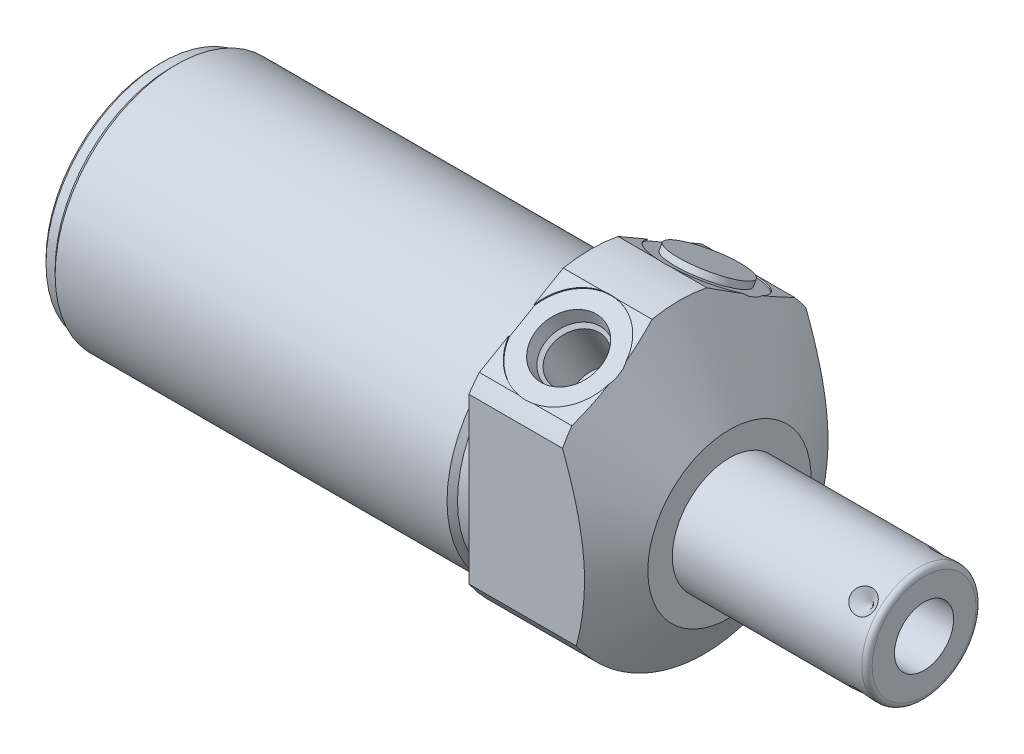
from build123d import *

# Parameters (mm, degrees)
SKETCH1_R           = 28.575
EXTRUDE1_DEPTH      = 27.0002
EXTRUDE1_DEPTH_BACK = 84.1248
CUT_EXTRUDE1_REACH  = 86.125
SKETCH2_R           = 28.575
SKETCH2_R_2         = 23.622
CUT_EXTRUDE3_START  = -27.0002
CUT_EXTRUDE3_DEPTH  = 27.0002
SKETCH18_R          = 9.525
CUT_EXTRUDE4_DEPTH  = 0.254
SKETCH19_R          = 9.525
CUT_EXTRUDE5_DEPTH  = 0.254
CHAMFER1_SIZE       = 0.762
SKETCH15_R          = 6.9469
EXTRUDE2_DEPTH      = 1.27
CIRPATTERN1_COUNT   = 4


with BuildPart() as part:
    # Sketch1 → Extrude1 (new body, two sides)
    with BuildSketch(Plane(origin=(0, 0, 0), x_dir=(0, 0, -1), z_dir=(1, 0, 0))) as extrude1_sk:
        Circle(SKETCH1_R)
    extrude(amount=EXTRUDE1_DEPTH)
    extrude(extrude1_sk.sketch, amount=-EXTRUDE1_DEPTH_BACK)

    # Sketch2 → Cut-Extrude1 (cut, up to next)
    with BuildSketch(Plane(origin=(0, 0, 0), x_dir=(0, 0, -1), z_dir=(1, 0, 0)), mode=Mode.PRIVATE) as cut_extrude1_sk1:
        Circle(SKETCH2_R)
        with Locations((0, -4.191)):
            Circle(SKETCH2_R_2, mode=Mode.SUBTRACT)
    cut_extrude1_tool1 = extrude(cut_extrude1_sk1.sketch, amount=-CUT_EXTRUDE1_REACH, mode=Mode.PRIVATE) & part.part
    add(cut_extrude1_tool1.solids().sort_by_distance((0, 0, 27.766777))[0], mode=Mode.SUBTRACT)

    # Sketch4 → Cut-Extrude3 (cut)
    with BuildSketch(Plane.ZY.offset(CUT_EXTRUDE3_START)):
        with BuildLine():
            Line((23.6855, -25.666178421), (23.6855, 17.476089577))
            Line((23.6855, 17.476089577), (0, 31.150919378))
            Line((0, 31.150919378), (-23.6855, 17.476089577))
            Line((-23.6855, 17.476089577), (-23.6855, -25.666178421))
            ThreePointArc((-23.6855, -25.666178421), (0, 34.925), (23.6855, -25.666178421))
        make_face()
    extrude(amount=CUT_EXTRUDE3_DEPTH, mode=Mode.SUBTRACT)

    # Sketch6 → Cut-Revolve2 (revolve, cut)
    with BuildSketch(Plane.XY, mode=Mode.PRIVATE) as cut_revolve2_sk:
        Polygon((0.750392661, 57.15), (27.0002, 11.684), (27.0002, 57.15), align=None)
    revolve(cut_revolve2_sk.sketch.rotate(Axis((-0.562097706, -4.191, 0), (1, 0, 0)), 270), axis=Axis((-0.562097706, -4.191, 0), (1, 0, 0)), mode=Mode.SUBTRACT)  # turned: the seam where the file's is

    # S2D0002 → Cut-Revolve3 (revolve, cut)
    with BuildSketch(Plane(origin=(9.0932, 23.136869081, 13.372742289), x_dir=(0, 0.5, -0.866025404), z_dir=(1, 0, 0))):
        Polygon((0, 0), (6.1849, 0), (5.642306865, -2.5527), (4.9784, -3.216606865), (4.9784, -13.462), (0, -13.462), align=None)
    revolve(axis=Axis((9.0932, 10.895513396, 6.305192289), (0, 0.866025404, 0.5)), mode=Mode.SUBTRACT)

    # Sketch8 → Cut-Revolve4 (revolve, cut)
    with BuildSketch(Plane(origin=(9.0932, 23.136869081, -13.372742289), x_dir=(0, -0.5, -0.866025404), z_dir=(1, 0, 0))):
        Polygon((0, 0), (6.1849, 0), (5.642306865, -2.5527), (4.9784, -3.216606865), (4.9784, -13.462), (0, -13.462), align=None)
    revolve(axis=Axis((9.0932, 10.895513396, -6.305192289), (0, 0.866025404, -0.5)), mode=Mode.SUBTRACT)

    # Sketch18 → Cut-Extrude4 (cut)
    with BuildSketch(Plane(origin=(0, 23.363189534, 13.488743766), x_dir=(1, 0, 0), z_dir=(0, 0.866025404, 0.5))):
        with Locations((9.0932, -0.0127)):
            Circle(SKETCH18_R)
    extrude(amount=-CUT_EXTRUDE4_DEPTH, mode=Mode.SUBTRACT)

    # Sketch19 → Cut-Extrude5 (cut)
    with BuildSketch(Plane(origin=(0, 23.363189534, -13.488743766), x_dir=(1, 0, 0), z_dir=(0, 0.866025404, -0.5))):
        with Locations((9.0932, 0.0127)):
            Circle(SKETCH19_R)
    extrude(amount=-CUT_EXTRUDE5_DEPTH, mode=Mode.SUBTRACT)

    # Sketch10 → Cut-Revolve6 (revolve, cut)
    with BuildSketch(Plane.XY, mode=Mode.PRIVATE) as cut_revolve6_sk:
        Polygon((0, 19.431), (0, 18.415), (-3.302, 18.415), (-4.318, 19.431), align=None)
    revolve(cut_revolve6_sk.sketch.rotate(Axis((-4.5339, -4.191, 0), (1, 0, 0)), 90), axis=Axis((-4.5339, -4.191, 0), (1, 0, 0)), mode=Mode.SUBTRACT)  # turned: the seam where the file's is

    # Sketch12 → Cut-Revolve8 (revolve, cut)
    with BuildSketch(Plane.XY, mode=Mode.PRIVATE) as cut_revolve8_sk:
        Polygon((-84.1248, 19.431), (-84.1248, 18.415), (-81.5848, 18.415), (-80.5688, 19.431), align=None)
    revolve(cut_revolve8_sk.sketch.rotate(Axis((-84.3026, -4.191, 0), (1, 0, 0)), 90), axis=Axis((-84.3026, -4.191, 0), (1, 0, 0)), mode=Mode.SUBTRACT)  # turned: the seam where the file's is

    # Chamfer1
    chamfer1_edges = [part.edges().sort_by_distance(p)[0] for p in [
        (-84.1248, -4.191, -22.606),
    ]]
    chamfer(chamfer1_edges, length=CHAMFER1_SIZE)

    # Sketch13 → Revolve1 (revolve)
    with BuildSketch(Plane(origin=(0, 0, 0), x_dir=(0, -1, 0), z_dir=(0, 0, 1)), mode=Mode.PRIVATE) as revolve1_sk:
        with BuildLine():
            Line((4.191, 27.0002), (4.191, 64.8716))
            Line((4.191, 64.8716), (14.2875, 64.8716))
            ThreePointArc((14.2875, 64.8716), (15.00592049, 64.57402049), (15.3035, 63.8556))
            Line((15.3035, 63.8556), (15.3035, 27.0002))
            Line((15.3035, 27.0002), (4.191, 27.0002))
        make_face()
    revolve(revolve1_sk.sketch.rotate(Axis((25.10663, -4.191, 0), (1, 0, 0)), 270), axis=Axis((25.10663, -4.191, 0), (1, 0, 0)))  # turned: the seam where the file's is

    # S2D0001 → Cut-Revolve9 (revolve, cut)
    with BuildSketch(Plane(origin=(64.8716, -9.9441, 0), x_dir=(0, -1, 0), z_dir=(0, 0, 1)), mode=Mode.PRIVATE) as cut_revolve9_sk:
        Polygon((0, 0), (0, -17.018), (-5.7531, -20.474811227), (-5.7531, 0), align=None)
    revolve(cut_revolve9_sk.sketch.rotate(Axis((43.373048211, -4.191, 0), (1, 0, 0)), 270), axis=Axis((43.373048211, -4.191, 0), (1, 0, 0)), mode=Mode.SUBTRACT)  # turned: the seam where the file's is

    # Sketch15 → Extrude2 (add)
    with BuildSketch(Plane(origin=(27.0002, 23.143219081, -13.361743766), x_dir=(0, -0.5, -0.866025404), z_dir=(0, -0.866025404, 0.5))):
        with Locations((0.0127, -17.907)):
            Circle(SKETCH15_R)
    extrude(amount=-EXTRUDE2_DEPTH)

    # Sketch16 → Cut-Revolve10 (revolve, cut)
    with BuildSketch(Plane(origin=(60.9092, 3.666724106, -7.857724106), x_dir=(-1, 0, 0), z_dir=(0, -0.707106781, -0.707106781)), mode=Mode.PRIVATE) as cut_revolve10_sk:
        Polygon((0, 0), (2.413, 0), (0, -2.413), align=None)
    cut_revolve10 = revolve(cut_revolve10_sk.sketch.rotate(Axis((60.9092, 0.494324135, -4.685324135), (0, 0.707106781, -0.707106781)), 90), axis=Axis((60.9092, 0.494324135, -4.685324135), (0, 0.707106781, -0.707106781)), mode=Mode.SUBTRACT)  # turned: the seam where the file's is

    # CirPattern1: Cut-Revolve10 ×4 about axis
    cirpattern1_axis = Axis((25.10663, -4.191, 0), (-1, 0, 0))
    for i in range(1, CIRPATTERN1_COUNT):
        add(cut_revolve10.rotate(cirpattern1_axis, i * 360 / CIRPATTERN1_COUNT), mode=Mode.SUBTRACT)


solid = part.part
